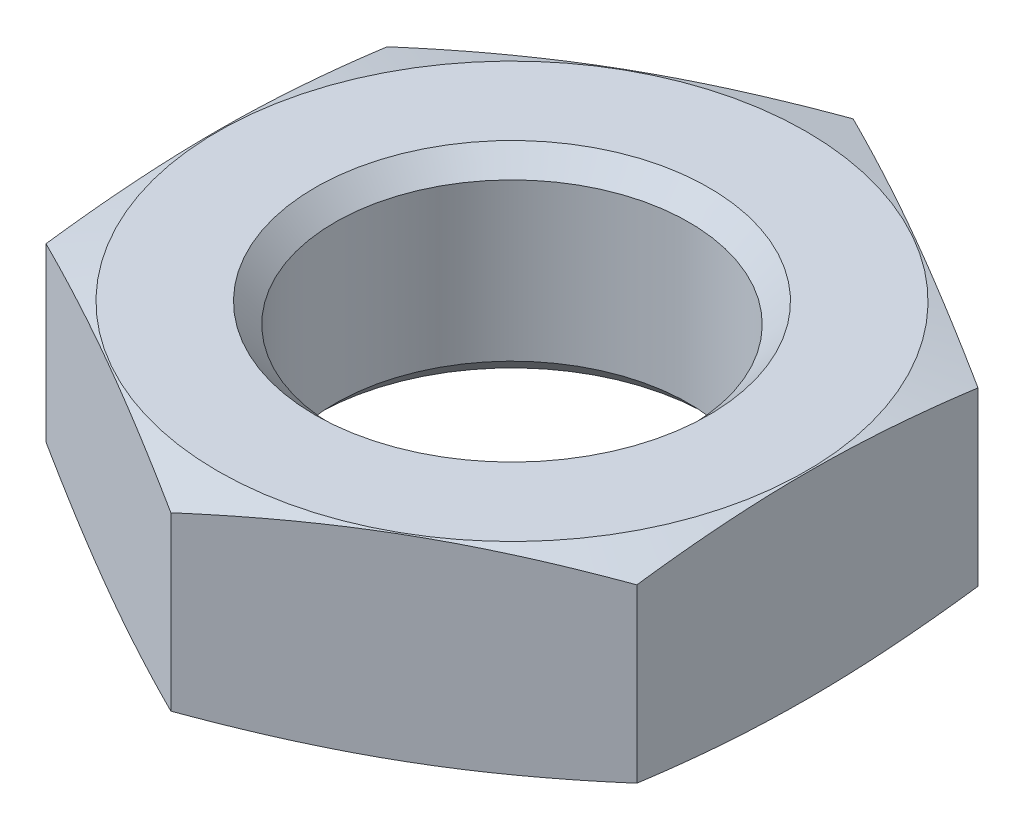
from build123d import *

# Parameters (mm, degrees)
CUT_EXTRUDE1_DEPTH      = 9
CUT_EXTRUDE1_DEPTH_BACK = 9
SKETCH2_W               = 96
SKETCH2_H               = 96


with BuildPart() as part:
    # Sketch1 → Revolve1 (revolve)
    with BuildSketch(Plane.XY):
        Polygon((0, 0), (11.95, 0), (26.87820323, -4), (11.95, -8), (0, -8), align=None)
    revolve(axis=Axis((0, -8, 0), (0, 1, 0)))

    # Sketch2 → Cut-Extrude1 (cut, two sides: drawn at the far end of the back side and taken through both)
    with BuildSketch(Plane(origin=(0, 0, 0), x_dir=(1, 0, 0), z_dir=(0, 1, 0)).offset(-CUT_EXTRUDE1_DEPTH_BACK)):
        Rectangle(SKETCH2_W, SKETCH2_H)
        Polygon((-12, -6.92820323), (0, -13.856406461), (12, -6.92820323), (12, 6.92820323), (0, 13.856406461), (-12, 6.92820323), align=None, mode=Mode.SUBTRACT)
    extrude(amount=CUT_EXTRUDE1_DEPTH + CUT_EXTRUDE1_DEPTH_BACK, mode=Mode.SUBTRACT)

    # Sketch3 → Cut-Revolve1 (revolve, cut)
    with BuildSketch(Plane.XY):
        Polygon((0, 0), (8, 0), (7.188, -0.812), (7.188, -7.188), (8, -8), (0, -8), align=None)
    revolve(axis=Axis((0, -8, 0), (0, 1, 0)), mode=Mode.SUBTRACT)


solid = part.part
